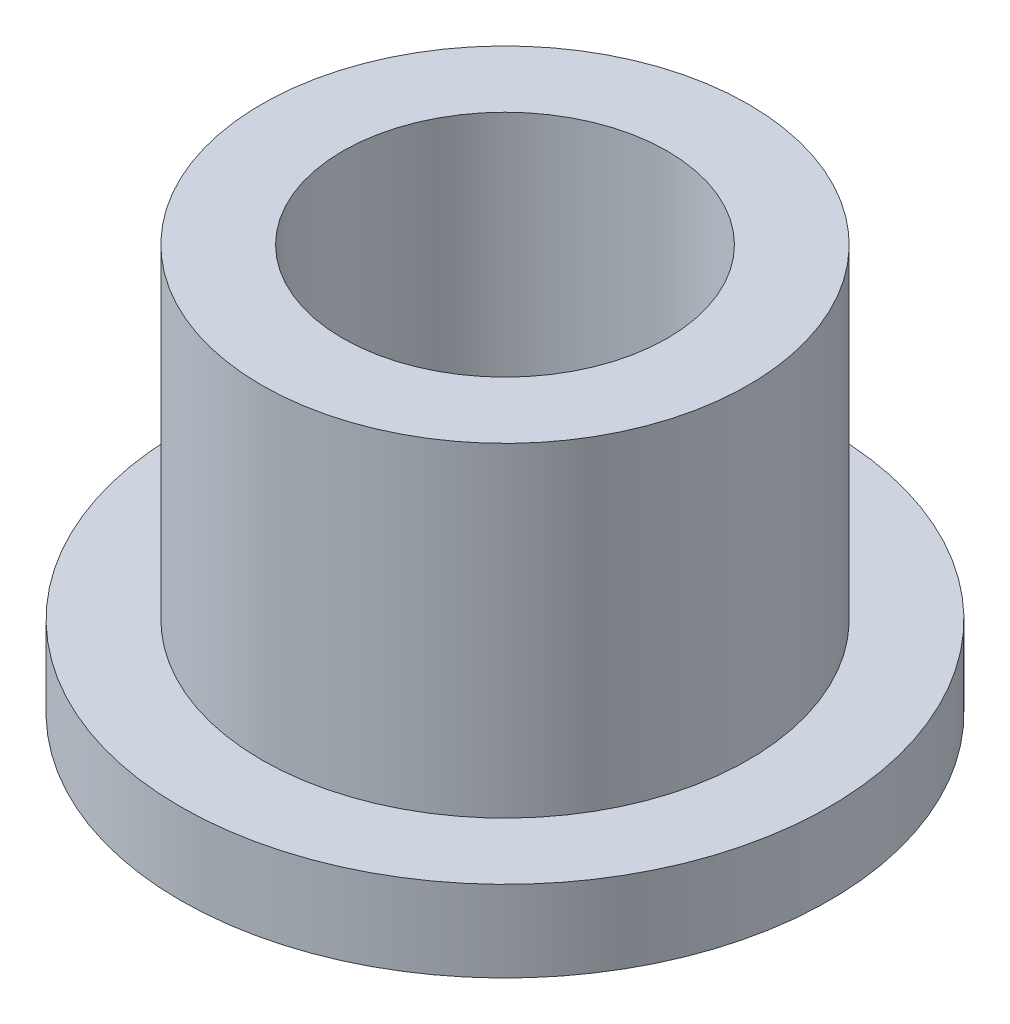
from build123d import *

# Parameters (mm, degrees)
SKETCH2_R           = 4.7625
SKETCH2_R_2         = 3.175
BOSS_EXTRUDE1_DEPTH = 7.9375
SKETCH3_R           = 6.35
SKETCH3_R_2         = 4.7625
BOSS_EXTRUDE2_DEPTH = 1.5875


with BuildPart() as part:
    # Sketch2 → Boss-Extrude1 (new body)
    with BuildSketch(Plane(origin=(0, 0, 0), x_dir=(1, 0, 0), z_dir=(0, 1, 0))):
        Circle(SKETCH2_R)
        Circle(SKETCH2_R_2, mode=Mode.SUBTRACT)
    extrude(amount=BOSS_EXTRUDE1_DEPTH)

    # Sketch3 → Boss-Extrude2 (add)
    with BuildSketch(Plane(origin=(0, 0, 0), x_dir=(1, 0, 0), z_dir=(0, 1, 0))):
        Circle(SKETCH3_R)
        Circle(SKETCH3_R_2, mode=Mode.SUBTRACT)
    extrude(amount=BOSS_EXTRUDE2_DEPTH)


solid = part.part
